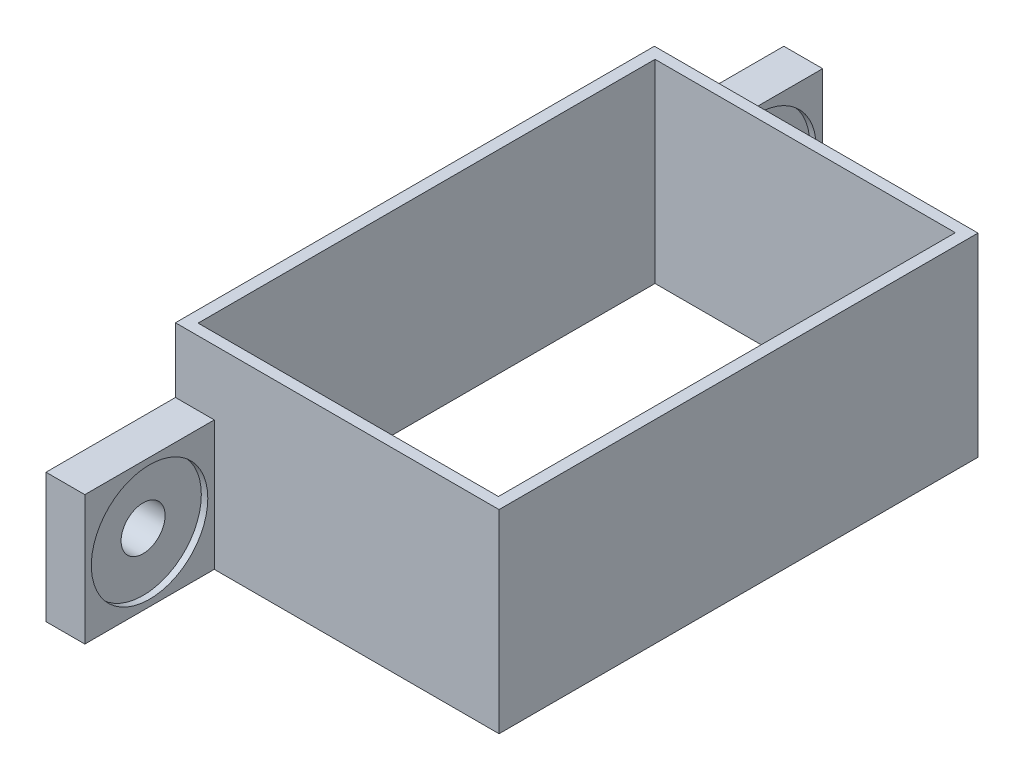
from build123d import *

# Parameters (mm, degrees)
SKETCH1_W                                            = 25
SKETCH1_H                                            = 37
BOSS_EXTRUDE2_DEPTH                                  = 20
SKETCH4_W                                            = 23.2
SKETCH4_H                                            = 35.3
CUT_EXTRUDE1_DEPTH                                   = 18
SKETCH30_W                                           = 10
SKETCH30_H                                           = 10
BOSS_EXTRUDE5_DEPTH                                  = 3
CBORE_FOR_M3_HEXAGON_HEAD_BOLTS_FULL_THR_D           = 3.4
CBORE_FOR_M3_HEXAGON_HEAD_BOLTS_FULL_THR_CBORE_D     = 9
CBORE_FOR_M3_HEXAGON_HEAD_BOLTS_FULL_THR_CBORE_DEPTH = 0.5
SKETCH32_W                                           = 25
SKETCH32_H                                           = 37
CUT_EXTRUDE2_DEPTH                                   = 5


with BuildPart() as part:
    # Sketch1 → Boss-Extrude2 (new body)
    with BuildSketch(Plane(origin=(0, 0, 0), x_dir=(1, 0, 0), z_dir=(0, 1, 0))):
        with Locations((-76.226170177, 10.94482429)):
            Rectangle(SKETCH1_W, SKETCH1_H)
    extrude(amount=BOSS_EXTRUDE2_DEPTH)

    # Sketch4 → Cut-Extrude1 (cut)
    with BuildSketch(Plane(origin=(0, 20, 0), x_dir=(1, 0, 0), z_dir=(0, 1, 0))):
        with Locations((-76.226170177, 10.94482429)):
            Rectangle(SKETCH4_W, SKETCH4_H)
    extrude(amount=-CUT_EXTRUDE1_DEPTH, mode=Mode.SUBTRACT)

    # Sketch30 → Boss-Extrude5 (add)
    with BuildSketch(Plane.ZY.offset(88.726170177)):
        with Locations((-34.44482429, 10)):
            Rectangle(SKETCH30_W, SKETCH30_H)
        with Locations((12.55517571, 10)):
            Rectangle(SKETCH30_W, SKETCH30_H)
    extrude(amount=-BOSS_EXTRUDE5_DEPTH)

    # CBORE for M3 Hexagon head bolts-Full thread-grades AB5 (through all)
    with Locations(Plane(origin=(-85.726170177, 10, -34.44482429), x_dir=(0, 0, 1), z_dir=(1, 0, 0))):
        with Locations((0, 0), (47, 0)):
            CounterBoreHole(CBORE_FOR_M3_HEXAGON_HEAD_BOLTS_FULL_THR_D / 2, CBORE_FOR_M3_HEXAGON_HEAD_BOLTS_FULL_THR_CBORE_D / 2, CBORE_FOR_M3_HEXAGON_HEAD_BOLTS_FULL_THR_CBORE_DEPTH)

    # Sketch32 → Cut-Extrude2 (cut)
    with BuildSketch(Plane.XZ):
        with Locations((-76.226170177, -10.94482429)):
            Rectangle(SKETCH32_W, SKETCH32_H)
    extrude(amount=-CUT_EXTRUDE2_DEPTH, mode=Mode.SUBTRACT)


solid = part.part
